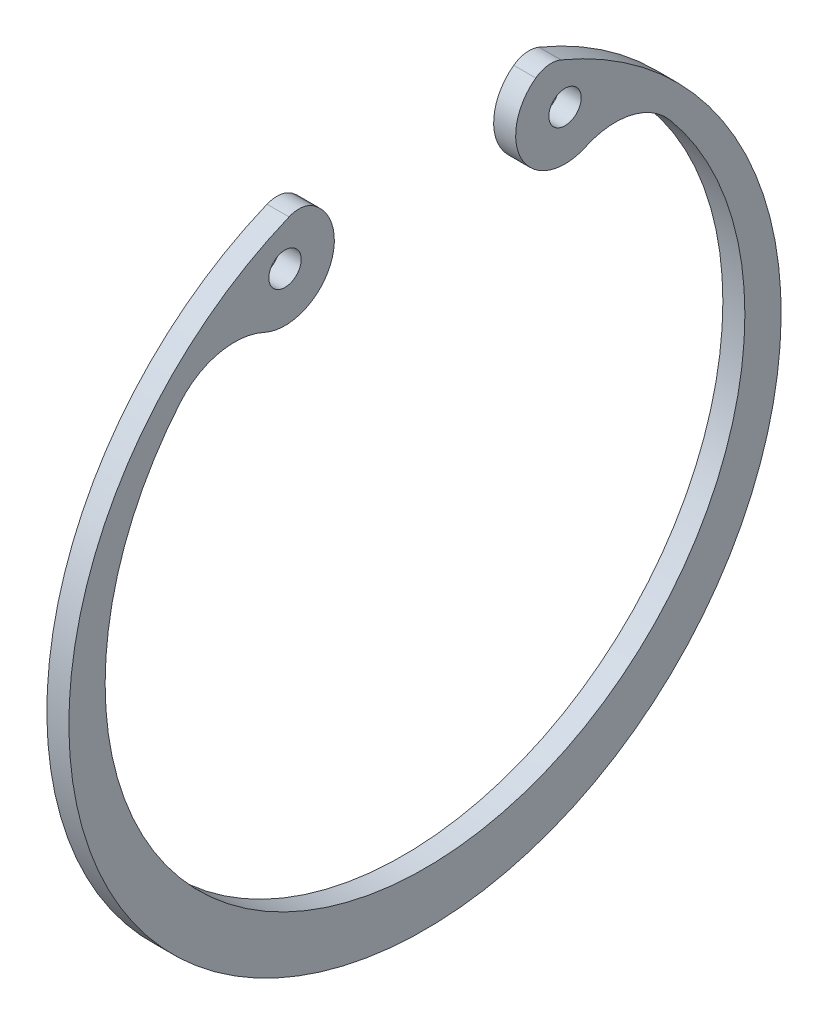
from build123d import *

# Parameters (mm, degrees)
SKETCH_1_R      = 1.25
EXTRUDE_1_DEPTH = 1.7


with BuildPart() as part:
    # Эскиз1 → Бобышка-Вытянуть1 (new body)
    with BuildSketch(Plane(origin=(0, 0, 0), x_dir=(0, 0, -1), z_dir=(1, 0, 0))):
        with BuildLine():
            ThreePointArc((-10.501041402, 25.416099808), (0, -27.5), (10.501041402, 25.416099808))
            ThreePointArc((10.501041402, 25.416099808), (9.49514864, 25.55293917), (8.55165041, 25.17829754))
            ThreePointArc((8.55165041, 25.17829754), (7.528235251, 20.173559762), (12.403088301, 18.646933891))
            ThreePointArc((12.403088301, 18.646933891), (15.90410896, 19.016751997), (18.912183735, 17.187709287))
            ThreePointArc((18.912183735, 17.187709287), (0, -23.4), (-18.912183735, 17.187709287))
            ThreePointArc((-18.912183735, 17.187709287), (-15.90410896, 19.016751997), (-12.403088301, 18.646933891))
            ThreePointArc((-12.403088301, 18.646933891), (-7.528235251, 20.173559762), (-8.55165041, 25.17829754))
            ThreePointArc((-8.55165041, 25.17829754), (-9.49514864, 25.55293917), (-10.501041402, 25.416099808))
        make_face()
        with Locations((10.810905529, 22.10929652)):
            Circle(SKETCH_1_R, mode=Mode.SUBTRACT)
        with Locations((-10.810905529, 22.10929652)):
            Circle(SKETCH_1_R, mode=Mode.SUBTRACT)
    extrude(amount=EXTRUDE_1_DEPTH)


solid = part.part
